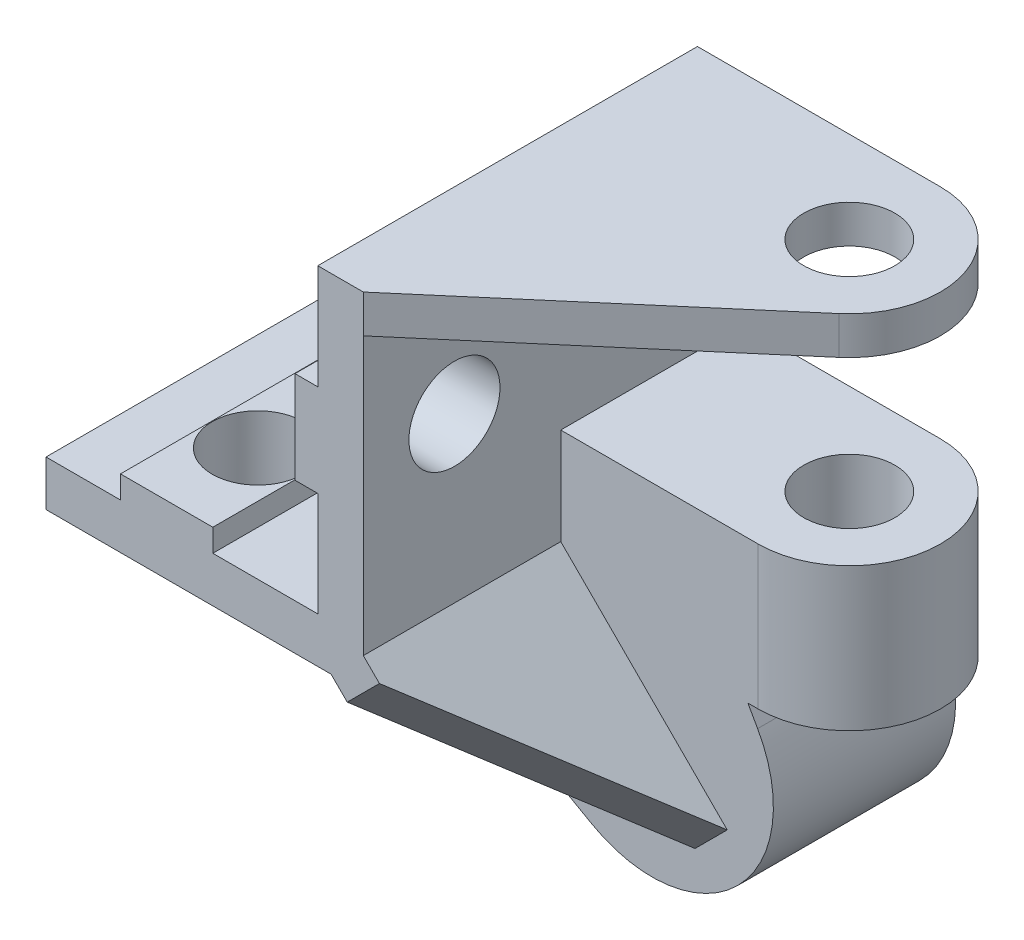
from build123d import *

# Parameters (mm, degrees)
BOSS_EXTRUDE1_DEPTH      = 25
SKETCH2_R                = 3
CUT_EXTRUDE1_DEPTH       = 15
SKETCH3_R                = 3
CUT_EXTRUDE2_DEPTH       = 15
BOSS_EXTRUDE2_DEPTH      = 12
BOSS_EXTRUDE4_DEPTH      = 1.5
SKETCH6_R                = 4.85
CUT_EXTRUDE3_DEPTH       = 9
BOSS_EXTRUDE5_DEPTH      = 2
BOSS_EXTRUDE5_DEPTH_BACK = 0.5
BOSS_EXTRUDE6_START      = -21.77874333
BOSS_EXTRUDE6_DEPTH      = 9.40874333
BOSS_EXTRUDE7_START      = -2.5
BOSS_EXTRUDE7_DEPTH      = 2.5
SKETCH10_R               = 3
CUT_EXTRUDE4_DEPTH       = 21


with BuildPart() as part:
    # Sketch1 → Boss-Extrude1 (new body)
    with BuildSketch(Plane.XY):
        Polygon((227.088719843, 62.282971172), (227.088719843, 57.379571172), (225.590119843, 57.379571172), (225.590119843, 51.299571172), (227.088719843, 51.299571172), (227.088719843, 44.429550862), (220.178702595, 44.429550862), (220.178702595, 45.917195068), (214.098687419, 45.917195068), (214.098687419, 44.429550862), (209.19527518, 44.429550862), (209.19527518, 41.429550862), (230.088719843, 41.429550862), (230.088719843, 62.282971172), align=None)
    extrude(amount=-BOSS_EXTRUDE1_DEPTH)

    # Sketch2 → Cut-Extrude1 (cut)
    with BuildSketch(Plane(origin=(230.088719843, 0, 0), x_dir=(0, 0, -1), z_dir=(1, 0, 0))):
        with Locations((6, 54.339571172)):
            Circle(SKETCH2_R)
    extrude(amount=-CUT_EXTRUDE1_DEPTH, mode=Mode.SUBTRACT)

    # Sketch3 → Cut-Extrude2 (cut)
    with BuildSketch(Plane.XZ.offset(-41.429550862)):
        with Locations((217.138695007, -6)):
            Circle(SKETCH3_R)
    extrude(amount=-CUT_EXTRUDE2_DEPTH, mode=Mode.SUBTRACT)

    # Sketch4 → Boss-Extrude2 (add)
    with BuildSketch(Plane(origin=(0, 0, -25), x_dir=(-1, 0, 0), z_dir=(0, 0, -1))):
        with BuildLine():
            Line((-237.925828106, 48.429550862), (-243.051733392, 39.368642422))
            ThreePointArc((-243.051733392, 39.368642422), (-241.747687926, 29.774811236), (-232.154834185, 28.463594817))
            Line((-232.154834185, 28.463594817), (-209.19527518, 41.429550862))
            Line((-209.19527518, 41.429550862), (-230.088719843, 41.429550862))
            Line((-230.088719843, 41.429550862), (-230.088719843, 48.429550862))
            Line((-230.088719843, 48.429550862), (-237.925828106, 48.429550862))
        make_face()
    extrude(amount=-BOSS_EXTRUDE2_DEPTH)

    # Sketch5 → Boss-Extrude4 (add, symmetric)
    with BuildSketch(Plane(origin=(135.717402312, 135.766641949, 0), x_dir=(0.7072350190117405, -0.7069785201004788, 0), z_dir=(-0.7069785201004788, -0.7072350190117405, 0))):
        Polygon((133.436997596, -13), (147.436997596, -13), (133.436997596, 0), (129.194356979, 0), (129.194356979, -13), align=None)
    extrude(amount=BOSS_EXTRUDE4_DEPTH, both=True)

    # Sketch6 → Cut-Extrude3 (cut)
    with BuildSketch(Plane(origin=(0, 0, -25), x_dir=(-1, 0, 0), z_dir=(0, 0, -1))):
        with Locations((-236.088719843, 35.429550862)):
            Circle(SKETCH6_R)
    extrude(amount=-CUT_EXTRUDE3_DEPTH, mode=Mode.SUBTRACT)

    # Sketch8 → Boss-Extrude5 (add, two sides: drawn at the far end of the back side and taken through both)
    with BuildSketch(Plane(origin=(0, 62.282971172, 0), x_dir=(-1, 0, 0), z_dir=(0, 1, 0)).offset(-BOSS_EXTRUDE5_DEPTH_BACK)):
        with BuildLine():
            Line((-227.088719843, -25), (-243.088719843, -25))
            ThreePointArc((-243.088719843, -25), (-249.088719843, -19), (-243.088719843, -13))
            Line((-243.088719843, -13), (-227.088719843, -13))
            Line((-227.088719843, -13), (-227.088719843, -25))
        make_face()
    extrude(amount=BOSS_EXTRUDE5_DEPTH + BOSS_EXTRUDE5_DEPTH_BACK)

    # Sketch8_2 → Boss-Extrude6 (add)
    with BuildSketch(Plane(origin=(0, 62.282971172, 0), x_dir=(-1, 0, 0), z_dir=(0, 1, 0)).offset(BOSS_EXTRUDE6_START)):
        with BuildLine():
            Line((-227.088719843, -25), (-243.088719843, -25))
            ThreePointArc((-243.088719843, -25), (-249.088719843, -19), (-243.088719843, -13))
            Line((-243.088719843, -13), (-227.088719843, -13))
            Line((-227.088719843, -13), (-227.088719843, -25))
        make_face()
    extrude(amount=BOSS_EXTRUDE6_DEPTH)

    # Sketch9 → Boss-Extrude7 (add)
    with BuildSketch(Plane(origin=(0, 64.282971172, 0), x_dir=(-1, 0, 0), z_dir=(0, 1, 0)).offset(BOSS_EXTRUDE7_START)):
        with BuildLine():
            Line((-227.088719843, -13), (-227.088719843, 0))
            Line((-227.088719843, 0), (-230.088719843, 0))
            Line((-230.088719843, 0), (-246.986411594, -14.438421434))
            ThreePointArc((-246.986411594, -14.438421434), (-245.166041268, -13.371080415), (-243.088719843, -13))
            Line((-243.088719843, -13), (-227.088719843, -13))
        make_face()
    extrude(amount=BOSS_EXTRUDE7_DEPTH)

    # Sketch10 → Cut-Extrude4 (cut)
    with BuildSketch(Plane(origin=(0, 64.282971172, 0), x_dir=(-1, 0, 0), z_dir=(0, 1, 0))):
        with Locations((-243.088719843, -19)):
            Circle(SKETCH10_R)
    extrude(amount=-CUT_EXTRUDE4_DEPTH, mode=Mode.SUBTRACT)


solid = part.part
